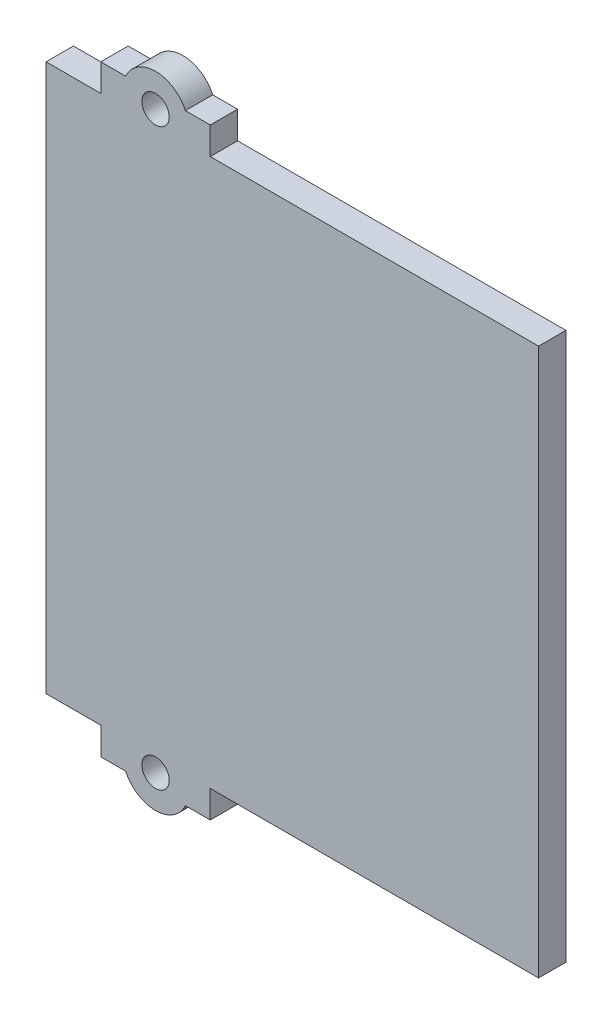
from build123d import *

# Parameters (mm, degrees)
SKETCH1_W           = 90
SKETCH1_H           = 100
BOSS_EXTRUDE1_DEPTH = 5
SKETCH2_W           = 20
SKETCH2_H           = 5
BOSS_EXTRUDE2_DEPTH = 5
SKETCH3_R           = 6
BOSS_EXTRUDE3_DEPTH = 5
SKETCH4_R           = 2.5
CUT_EXTRUDE1_DEPTH  = 5


with BuildPart() as part:
    # Sketch1 → Boss-Extrude1 (new body)
    with BuildSketch(Plane.XY):
        Rectangle(SKETCH1_W, SKETCH1_H)
    extrude(amount=BOSS_EXTRUDE1_DEPTH)

    # Sketch2 → Boss-Extrude2 (add)
    with BuildSketch(Plane(origin=(0, 50, 0), x_dir=(1, 0, 0), z_dir=(0, 1, 0))):
        with Locations((-25, -2.5)):
            Rectangle(SKETCH2_W, SKETCH2_H)
    boss_extrude2 = extrude(amount=BOSS_EXTRUDE2_DEPTH)

    # Mirror1: Boss-Extrude2 across plane
    add(boss_extrude2.mirror(Plane.ZX))

    # Sketch3 → Boss-Extrude3 (add)
    with BuildSketch(Plane.XY.offset(5)):
        with Locations((-25, 52.5)):
            Circle(SKETCH3_R)
    boss_extrude3 = extrude(amount=-BOSS_EXTRUDE3_DEPTH)

    # Sketch4 → Cut-Extrude1 (cut)
    with BuildSketch(Plane.XY.offset(5)):
        with Locations((-25, 52.5)):
            Circle(SKETCH4_R)
    cut_extrude1 = extrude(amount=-CUT_EXTRUDE1_DEPTH, mode=Mode.SUBTRACT)

    # Mirror2: Boss-Extrude3, Cut-Extrude1 across plane
    add(boss_extrude3.mirror(Plane.ZX))
    add(cut_extrude1.mirror(Plane.ZX), mode=Mode.SUBTRACT)


solid = part.part
